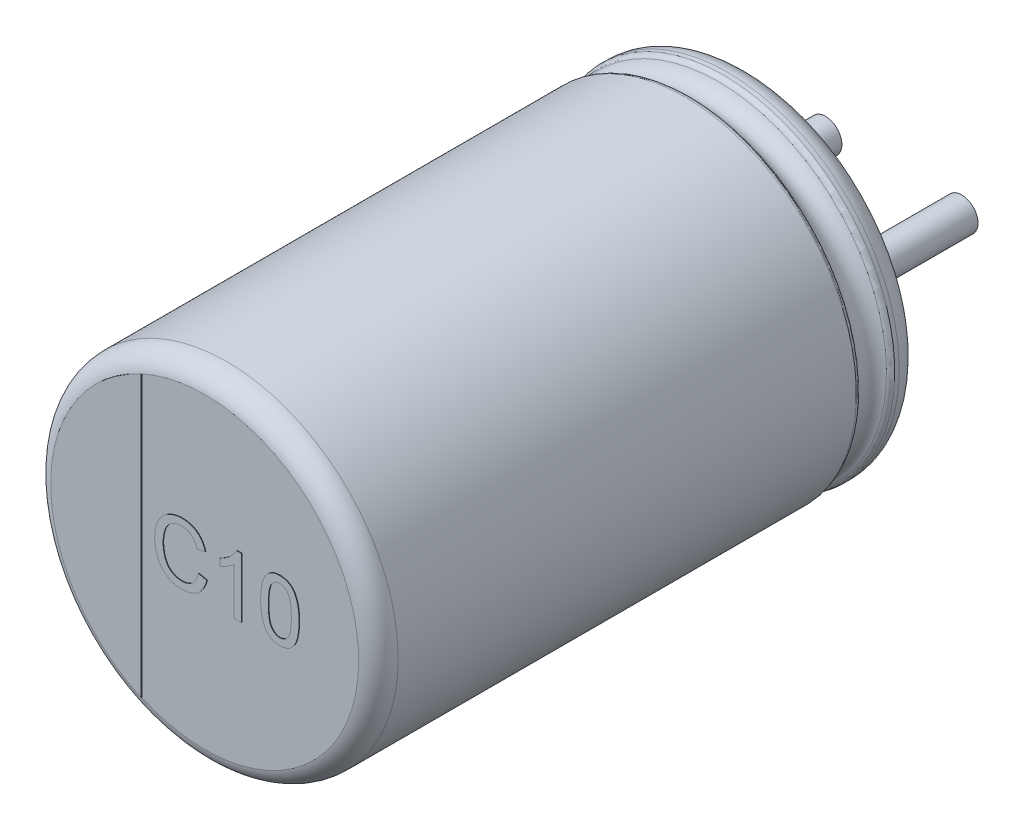
from build123d import *

# Parameters (mm, degrees)
SKETCH_2_R         = 0.3
EXTRUDE_1_DEPTH    = 2.7
EXTRUDE_2_DEPTH    = 0.01
EXTRUDE_1856_DEPTH = 0.01
EXTRUDE_5_DEPTH    = 0.05


with BuildPart() as part:
    # Sketch10 → Повернуть1 (revolve)
    with BuildSketch(Plane(origin=(0, 0, 0), x_dir=(0, 0, -1), z_dir=(1, 0, 0))):
        with BuildLine():
            Line((-10, 0), (-0.05, 0))
            Line((-0.05, 0), (-0.05, 2.553143426))
            ThreePointArc((-0.05, 2.553143426), (-0.052704561, 2.951565585), (-0.398206102, 3.15))
            Line((-0.398206102, 3.15), (-0.479422929, 3.15))
            ThreePointArc((-0.479422929, 3.15), (-0.534479696, 3.133479053), (-0.571344666, 3.089375046))
            ThreePointArc((-0.571344666, 3.089375046), (-0.831990181, 2.917472047), (-1.092635697, 3.089375046))
            ThreePointArc((-1.092635697, 3.089375046), (-1.129500666, 3.133479053), (-1.184557434, 3.15))
            Line((-1.184557434, 3.15), (-9.6, 3.15))
            ThreePointArc((-9.6, 3.15), (-9.85971595, 3.059961924), (-10, 2.82357323))
            Line((-10, 2.82357323), (-10, 0))
        make_face()
    revolve(axis=Axis((0, 0, -18.1630778), (0, 0, 1)))

    # Эскиз2 → Бобышка-Вытянуть1 (add)
    with BuildSketch(Plane(origin=(0, 0, 0.05), x_dir=(-1, 0, 0), z_dir=(0, 0, -1))):
        with Locations((-1.25, 0)):
            Circle(SKETCH_2_R)
        with Locations((1.25, 0)):
            Circle(SKETCH_2_R)
    extrude(amount=EXTRUDE_1_DEPTH)

    # Эскиз4 → Бобышка-Вытянуть2 (add)
    with BuildSketch(Plane.XY.offset(10)):
        with BuildLine():
            Line((-1.160332513, -2.574139515), (-1.160332513, 2.574139515))
            ThreePointArc((-1.160332513, 2.574139515), (-2.82357323, 0), (-1.160332513, -2.574139515))
        make_face()
    extrude(amount=EXTRUDE_2_DEPTH)

    # Эскиз5 → Extrude 1856 (add)
    with BuildSketch(Plane.XY.offset(10)):
        with BuildLine():
            Line((-0.108912855, -0.069918347), (0.04621535, -0.106056167))
            add(Edge.make_bspline(
                [(0.04621535, -0.106056167), (0.042328955, -0.120595903), (0.034726685, -0.149037431), (0.019696074, -0.189740405), (0.002826055, -0.22793841), (-0.016292712, -0.263530826), (-0.037869483, -0.296313018), (-0.061332559, -0.326706301), (-0.08761128, -0.354073299), (-0.115741448, -0.379045627), (-0.145942088, -0.401071154), (-0.177849082, -0.420090601), (-0.2113082, -0.436272289), (-0.246454673, -0.449579116), (-0.283311287, -0.459593644), (-0.321688266, -0.466892819), (-0.361697515, -0.471388685), (-0.388969191, -0.471980579), (-0.402863176, -0.472282129)],
                knots=[0, 0, 0, 0, 4.5129e-05, 8.8278e-05, 0.000130005, 0.00017033, 0.000209322, 0.000247627, 0.000285345, 0.000322969, 0.000360344, 0.000397303, 0.00043426, 0.000471708, 0.000509877, 0.000548685, 0.000588812, 0.000630487, 0.000630487, 0.000630487, 0.000630487], degree=3))
            add(Edge.make_bspline(
                [(-0.402863176, -0.472282129), (-0.417118674, -0.472075022), (-0.445008416, -0.471669834), (-0.48586528, -0.468374144), (-0.524724169, -0.462658281), (-0.561512517, -0.454716909), (-0.596354147, -0.444897895), (-0.629104581, -0.432544706), (-0.659706455, -0.417746474), (-0.68841503, -0.40091706), (-0.715108371, -0.381798088), (-0.740393493, -0.360905526), (-0.763656558, -0.337664227), (-0.785479231, -0.312622937), (-0.805386205, -0.285451329), (-0.824109863, -0.25651854), (-0.840736314, -0.225314775), (-0.855881721, -0.192418552), (-0.869175168, -0.158148367), (-0.880935219, -0.12318115), (-0.890549703, -0.087447226), (-0.898827154, -0.051247288), (-0.904840321, -0.01427674), (-0.90961459, 0.023187027), (-0.912239578, 0.061373697), (-0.912584999, 0.087042498), (-0.912759009, 0.09997348)],
                knots=[0, 0, 0, 0, 4.2763e-05, 8.3662e-05, 0.000122865, 0.000160509, 0.000196497, 0.000231366, 0.000265367, 0.000298359, 0.00033107, 0.000363769, 0.000396646, 0.000429606, 0.00046332, 0.000497611, 0.000532907, 0.000569289, 0.000606199, 0.00064313, 0.000679908, 0.000717169, 0.000754481, 0.000792226, 0.000830438, 0.00086923, 0.00086923, 0.00086923, 0.00086923], degree=3))
            add(Edge.make_bspline(
                [(-0.912759009, 0.09997348), (-0.912510138, 0.113932996), (-0.912018432, 0.141513475), (-0.909242757, 0.182209272), (-0.904144849, 0.221485694), (-0.897065337, 0.259368577), (-0.888106922, 0.295888601), (-0.877048763, 0.331063557), (-0.864030746, 0.364848441), (-0.849092557, 0.397280506), (-0.83213495, 0.427997725), (-0.81366404, 0.457043765), (-0.793239225, 0.483941703), (-0.771466071, 0.509205432), (-0.747800778, 0.532414283), (-0.72231561, 0.553620827), (-0.695230442, 0.573018497), (-0.666549228, 0.590427213), (-0.636646863, 0.605702449), (-0.605967495, 0.619308236), (-0.574389099, 0.630460027), (-0.542162036, 0.639732294), (-0.509216926, 0.647113879), (-0.475476789, 0.652049968), (-0.4409728, 0.655266706), (-0.417707516, 0.655702651), (-0.405948112, 0.655922999)],
                knots=[0, 0, 0, 0, 4.1881e-05, 8.2747e-05, 0.000122296, 0.00016063, 0.000198308, 0.000235036, 0.00027117, 0.000306859, 0.000342067, 0.000376357, 0.000410027, 0.000443298, 0.000476332, 0.000509341, 0.000542667, 0.000576187, 0.000609892, 0.00064334, 0.000676795, 0.000710271, 0.000743899, 0.000777992, 0.000812505, 0.000847779, 0.000847779, 0.000847779, 0.000847779], degree=3))
            add(Edge.make_bspline(
                [(-0.405948112, 0.655922999), (-0.392790923, 0.655674993), (-0.366929166, 0.655187511), (-0.328981645, 0.651177881), (-0.292637827, 0.64446219), (-0.25774023, 0.635651838), (-0.224651675, 0.623588633), (-0.19301293, 0.609246868), (-0.163138738, 0.592016975), (-0.134796652, 0.572372462), (-0.108448038, 0.5502771), (-0.083724175, 0.526258741), (-0.061633171, 0.499717103), (-0.04130009, 0.471294538), (-0.023364678, 0.440596924), (-0.007167108, 0.407891911), (0.006762331, 0.372936375), (0.014215274, 0.348588877), (0.018010222, 0.336191429)],
                knots=[0, 0, 0, 0, 3.9465e-05, 7.7573e-05, 0.00011431, 0.000150279, 0.000185409, 0.000219821, 0.000254368, 0.000288721, 0.000323141, 0.000357421, 0.000391983, 0.00042659, 0.000462151, 0.000498515, 0.000535996, 0.000574881, 0.000574881, 0.000574881, 0.000574881], degree=3))
            Line((0.018010222, 0.336191429), (-0.137117984, 0.302918192))
            add(Edge.make_bspline(
                [(-0.137117984, 0.302918192), (-0.140164459, 0.312432596), (-0.146127355, 0.331055231), (-0.15671506, 0.357595794), (-0.168149428, 0.382234108), (-0.180702836, 0.404802692), (-0.194402488, 0.425306953), (-0.20893292, 0.443996089), (-0.224642265, 0.460521265), (-0.241210981, 0.47526351), (-0.259066923, 0.487822492), (-0.277791469, 0.498951816), (-0.297779426, 0.508159635), (-0.318743252, 0.515947548), (-0.340878894, 0.521874989), (-0.364096214, 0.526045177), (-0.388415609, 0.528458678), (-0.404987911, 0.528817113), (-0.413440099, 0.528999922)],
                knots=[0, 0, 0, 0, 2.9963e-05, 5.8647e-05, 8.5657e-05, 0.000111404, 0.000136034, 0.000159573, 0.00018233, 0.000204345, 0.00022599, 0.00024772, 0.000269605, 0.000291914, 0.000314738, 0.000338251, 0.000362611, 0.000387967, 0.000387967, 0.000387967, 0.000387967], degree=3))
            add(Edge.make_bspline(
                [(-0.413440099, 0.528999922), (-0.423143984, 0.528859129), (-0.442228662, 0.528582229), (-0.47026635, 0.525551592), (-0.497192283, 0.52108776), (-0.522805782, 0.51439386), (-0.547247006, 0.506048307), (-0.570370917, 0.495656617), (-0.592374217, 0.483476338), (-0.613011338, 0.469434324), (-0.632108844, 0.453648399), (-0.650184985, 0.436960206), (-0.666371907, 0.418591447), (-0.681286864, 0.399147811), (-0.694495535, 0.378285716), (-0.706385552, 0.356289328), (-0.716881124, 0.332978371), (-0.72832201, 0.300169965), (-0.739987527, 0.257913496), (-0.750107378, 0.206205274), (-0.756553484, 0.153682392), (-0.757270938, 0.118354545), (-0.757630804, 0.100634538)],
                knots=[0, 0, 0, 0, 2.91e-05, 5.7231e-05, 8.4509e-05, 0.000110911, 0.000136555, 0.000161905, 0.00018686, 0.000211918, 0.000236663, 0.000261138, 0.00028564, 0.000310012, 0.000334585, 0.000359628, 0.000384977, 0.000411183, 0.00046379, 0.000516339, 0.000569145, 0.000622287, 0.000622287, 0.000622287, 0.000622287], degree=3))
            add(Edge.make_bspline(
                [(-0.757630804, 0.100634538), (-0.757224926, 0.078354594), (-0.756437487, 0.035129485), (-0.748667393, -0.027510838), (-0.73682082, -0.085937398), (-0.722523713, -0.131521756), (-0.708182278, -0.165145637), (-0.696583647, -0.188692925), (-0.683344271, -0.210482444), (-0.668793463, -0.230637938), (-0.652743794, -0.249100614), (-0.635418867, -0.265968548), (-0.616814812, -0.281404048), (-0.59671119, -0.29468455), (-0.575881813, -0.306476479), (-0.554589531, -0.316962087), (-0.53282094, -0.32583035), (-0.51048821, -0.332719396), (-0.487904955, -0.338672491), (-0.464822442, -0.342561331), (-0.441247254, -0.34475607), (-0.425417098, -0.345156447), (-0.417406445, -0.345359052)],
                knots=[0, 0, 0, 0, 6.6811e-05, 0.000129619, 0.000189041, 0.000245488, 0.000272541, 0.000298655, 0.000324164, 0.000348934, 0.000373146, 0.000397455, 0.000421409, 0.000445549, 0.000469628, 0.000493181, 0.000516709, 0.000540055, 0.00056325, 0.000586724, 0.000610185, 0.00063422, 0.00063422, 0.00063422, 0.00063422], degree=3))
            add(Edge.make_bspline(
                [(-0.417406445, -0.345359052), (-0.407846827, -0.345158567), (-0.388963202, -0.344762537), (-0.361277409, -0.34129607), (-0.334588687, -0.336187777), (-0.309220365, -0.328305166), (-0.284831211, -0.318653832), (-0.261621051, -0.306752049), (-0.239662879, -0.292437677), (-0.218698419, -0.276185053), (-0.199114272, -0.257692345), (-0.181166455, -0.237108537), (-0.165065235, -0.214339793), (-0.150135352, -0.189751516), (-0.137591507, -0.162609165), (-0.125972944, -0.133721734), (-0.116291518, -0.102614431), (-0.111407741, -0.080973603), (-0.108912855, -0.069918347)],
                knots=[0, 0, 0, 0, 2.8667e-05, 5.6627e-05, 8.3593e-05, 0.000110082, 0.000136188, 0.000162205, 0.000188181, 0.000214716, 0.000241683, 0.000268859, 0.000296498, 0.000325256, 0.000355023, 0.00038608, 0.000418627, 0.000452619, 0.000452619, 0.000452619, 0.000452619], degree=3))
        make_face()
        with BuildLine():
            Line((0.680830734, -0.458179565), (0.539805093, -0.458179565))
            Line((0.539805093, -0.458179565), (0.539805093, 0.39899191))
            add(Edge.make_bspline(
                [(0.539805093, 0.39899191), (0.531684824, 0.391160909), (0.514807735, 0.374885033), (0.486278799, 0.351850605), (0.454436861, 0.328504235), (0.419695408, 0.30605409), (0.384282373, 0.2849197), (0.350060235, 0.265912566), (0.317600345, 0.249827918), (0.296218841, 0.241032769), (0.285958939, 0.236812422)],
                knots=[0, 0, 0, 0, 3.3829e-05, 7.031e-05, 0.000109888, 0.000152243, 0.000194341, 0.000233594, 0.000269662, 0.000302936, 0.000302936, 0.000302936, 0.000302936], degree=3))
            Line((0.285958939, 0.236812422), (0.285958939, 0.366820435))
            add(Edge.make_bspline(
                [(0.285958939, 0.366820435), (0.30358138, 0.375896028), (0.338314168, 0.393783483), (0.387384086, 0.424677577), (0.433196134, 0.458168047), (0.474991939, 0.494247477), (0.512459216, 0.531127132), (0.544033433, 0.568340152), (0.57045273, 0.60452247), (0.583707791, 0.629755623), (0.590045478, 0.641820435)],
                knots=[0, 0, 0, 0, 5.9443e-05, 0.000117159, 0.000173749, 0.000229533, 0.000282665, 0.000331279, 0.00037585, 0.000416686, 0.000416686, 0.000416686, 0.000416686], degree=3))
            Line((0.590045478, 0.641820435), (0.680830734, 0.641820435))
            Line((0.680830734, 0.641820435), (0.680830734, -0.458179565))
        make_face()
        with BuildLine():
            add(Edge.make_bspline(
                [(1.033394837, 0.084328448), (1.03353692, 0.100048458), (1.033815202, 0.130837337), (1.035541291, 0.175886998), (1.038554904, 0.218668796), (1.043053398, 0.259145577), (1.048380458, 0.297408704), (1.055305669, 0.333403573), (1.063097538, 0.367210943), (1.072446383, 0.398795576), (1.082717703, 0.428429042), (1.094370843, 0.456063803), (1.107482207, 0.481670559), (1.121407451, 0.505514867), (1.136879631, 0.527225849), (1.152964876, 0.547412804), (1.170832165, 0.565335399), (1.189738538, 0.581454782), (1.209962397, 0.595679199), (1.231396738, 0.607953155), (1.253959086, 0.618790173), (1.278079455, 0.626948277), (1.303257111, 0.633598862), (1.329685859, 0.638491112), (1.357394822, 0.641375259), (1.376330004, 0.641670367), (1.385958939, 0.641820435)],
                knots=[0, 0, 0, 0, 4.716e-05, 9.2367e-05, 0.000135226, 0.000175791, 0.000214526, 0.000251087, 0.000285722, 0.000318563, 0.000349854, 0.000379772, 0.000408449, 0.000436112, 0.000462522, 0.000488367, 0.000513454, 0.00053831, 0.000562825, 0.000587506, 0.000612346, 0.000637782, 0.000663757, 0.000690424, 0.000718336, 0.000747215, 0.000747215, 0.000747215, 0.000747215], degree=3))
            add(Edge.make_bspline(
                [(1.385958939, 0.641820435), (1.400085841, 0.641405114), (1.427838706, 0.6405892), (1.468358031, 0.633934748), (1.506544884, 0.622551284), (1.542374454, 0.607194499), (1.575234241, 0.587688427), (1.604579416, 0.563975825), (1.630093444, 0.536305669), (1.651497878, 0.504350079), (1.670207489, 0.468990602), (1.686828698, 0.430068533), (1.701853788, 0.387627487), (1.712515918, 0.349636826), (1.720121207, 0.31684194), (1.725155304, 0.289793645), (1.729334614, 0.260608383), (1.73253653, 0.229356761), (1.735163627, 0.196073829), (1.737192413, 0.160738865), (1.73822223, 0.123263557), (1.738420892, 0.09755012), (1.738523042, 0.084328448)],
                knots=[0, 0, 0, 0, 4.2365e-05, 8.3228e-05, 0.000122759, 0.000161647, 0.00019989, 0.000237023, 0.00027445, 0.000312344, 0.000352072, 0.000394316, 0.000439198, 0.000487052, 0.000512602, 0.000540175, 0.000569562, 0.000601026, 0.000634404, 0.000669716, 0.000707192, 0.000746858, 0.000746858, 0.000746858, 0.000746858], degree=3))
            add(Edge.make_bspline(
                [(1.738523042, 0.084328448), (1.738378297, 0.068682277), (1.73809551, 0.038114404), (1.736415672, -0.006574035), (1.733220468, -0.049033065), (1.729288711, -0.089359948), (1.723340787, -0.127447029), (1.716931576, -0.163456131), (1.709004965, -0.197223741), (1.699756472, -0.228764657), (1.689340568, -0.258245658), (1.677917917, -0.285889544), (1.665266235, -0.311677426), (1.65100896, -0.335357781), (1.635798425, -0.357244927), (1.619523232, -0.377420967), (1.601838325, -0.39559551), (1.582761576, -0.411666544), (1.562679714, -0.42614321), (1.541193262, -0.438538347), (1.518396265, -0.448807503), (1.494441037, -0.45758712), (1.469084518, -0.464020309), (1.442526668, -0.468944815), (1.414669632, -0.471844721), (1.395661211, -0.472134314), (1.385958939, -0.472282129)],
                knots=[0, 0, 0, 0, 4.694e-05, 9.1706e-05, 0.000134126, 0.000174667, 0.000213216, 0.000249737, 0.000284372, 0.000317213, 0.000348296, 0.000378129, 0.000406904, 0.000434377, 0.000460968, 0.000486813, 0.000512057, 0.000536914, 0.000561556, 0.000586236, 0.000611184, 0.000636486, 0.000662674, 0.000689557, 0.000717469, 0.000746569, 0.000746569, 0.000746569, 0.000746569], degree=3))
            add(Edge.make_bspline(
                [(1.385958939, -0.472282129), (1.373238137, -0.471919267), (1.348436073, -0.471211787), (1.312214487, -0.466404895), (1.278218597, -0.457944539), (1.246161667, -0.446598009), (1.216404024, -0.431421372), (1.188803589, -0.412956029), (1.162805751, -0.391631596), (1.147839815, -0.374807108), (1.140265831, -0.366292546)],
                knots=[0, 0, 0, 0, 3.8162e-05, 7.4405e-05, 0.000109357, 0.000143093, 0.000176205, 0.000209268, 0.000242588, 0.000276728, 0.000276728, 0.000276728, 0.000276728], degree=3))
            add(Edge.make_bspline(
                [(1.140265831, -0.366292546), (1.131548, -0.353716948), (1.113571462, -0.327785527), (1.092531482, -0.283570049), (1.073763447, -0.234895016), (1.059033981, -0.180805429), (1.047497137, -0.12173178), (1.039164656, -0.057558155), (1.034449292, 0.011687722), (1.033754256, 0.059568265), (1.033394837, 0.084328448)],
                knots=[0, 0, 0, 0, 4.5838e-05, 9.4519e-05, 0.00014641, 0.000202225, 0.000262423, 0.000326872, 0.000396232, 0.000470512, 0.000470512, 0.000470512, 0.000470512], degree=3))
        make_face()
        with BuildLine():
            add(Edge.make_bspline(
                [(1.174420478, 0.084769153), (1.174560505, 0.063612152), (1.174828548, 0.023112973), (1.177628948, -0.034747093), (1.182449722, -0.086944769), (1.188823099, -0.133407787), (1.197238537, -0.174198995), (1.207805116, -0.209214445), (1.219716163, -0.238874403), (1.234455857, -0.262811255), (1.250594195, -0.282323282), (1.267255926, -0.299104255), (1.284833043, -0.313367699), (1.303210857, -0.325260502), (1.322674514, -0.334264951), (1.343011182, -0.340791396), (1.364225285, -0.344547265), (1.378673053, -0.345086912), (1.385958939, -0.345359052)],
                knots=[0, 0, 0, 0, 6.3468e-05, 0.000121491, 0.00017372, 0.000220682, 0.000262127, 0.000298514, 0.000330313, 0.000357712, 0.000382457, 0.00040614, 0.000428544, 0.000450244, 0.000471636, 0.000492682, 0.000514165, 0.000536019, 0.000536019, 0.000536019, 0.000536019], degree=3))
            add(Edge.make_bspline(
                [(1.385958939, -0.345359052), (1.393243002, -0.345080966), (1.407687152, -0.344529527), (1.428950272, -0.340856479), (1.449207814, -0.333994057), (1.468642451, -0.325021412), (1.487153841, -0.313399681), (1.504644631, -0.299082362), (1.521394133, -0.282311352), (1.537459977, -0.262572534), (1.552087376, -0.238525013), (1.56422186, -0.208889217), (1.574623764, -0.173812444), (1.58308538, -0.133042019), (1.589485048, -0.086652463), (1.594276674, -0.034599559), (1.597095815, 0.02318606), (1.597359435, 0.063612057), (1.597497401, 0.084769153)],
                knots=[0, 0, 0, 0, 2.1855e-05, 4.3338e-05, 6.4452e-05, 8.5844e-05, 0.000107426, 0.00012983, 0.000153513, 0.000178429, 0.000206016, 0.000237612, 0.000274209, 0.000315655, 0.000362399, 0.000414627, 0.000472431, 0.000535899, 0.000535899, 0.000535899, 0.000535899], degree=3))
            add(Edge.make_bspline(
                [(1.597497401, 0.084769153), (1.597363852, 0.105486039), (1.597107978, 0.145178808), (1.594216127, 0.201924198), (1.589684338, 0.253245758), (1.583485569, 0.299190802), (1.575247408, 0.339709451), (1.565255641, 0.374887963), (1.553348957, 0.404651314), (1.539191953, 0.429298478), (1.523432374, 0.449515839), (1.50697, 0.467015724), (1.48939327, 0.481898806), (1.470390777, 0.493838234), (1.450575007, 0.50347052), (1.429490644, 0.510099705), (1.407344931, 0.514172469), (1.392146615, 0.514652968), (1.384416472, 0.514897358)],
                knots=[0, 0, 0, 0, 6.2146e-05, 0.000119069, 0.0001704, 0.000216676, 0.000258077, 0.000294338, 0.000326256, 0.000353997, 0.000379296, 0.000402987, 0.000425981, 0.000448171, 0.00047015, 0.000491893, 0.000514282, 0.000537457, 0.000537457, 0.000537457, 0.000537457], degree=3))
            add(Edge.make_bspline(
                [(1.384416472, 0.514897358), (1.377131043, 0.514706145), (1.36276511, 0.514329095), (1.341731504, 0.510730166), (1.321798202, 0.504711955), (1.302736833, 0.496559703), (1.285023256, 0.485588382), (1.267954992, 0.472778584), (1.252331453, 0.457171275), (1.242916846, 0.445503494), (1.238102369, 0.439536781)],
                knots=[0, 0, 0, 0, 2.1843e-05, 4.3071e-05, 6.3776e-05, 8.4203e-05, 0.000105064, 0.00012613, 0.0001481, 0.000171094, 0.000171094, 0.000171094, 0.000171094], degree=3))
            add(Edge.make_bspline(
                [(1.238102369, 0.439536781), (1.232860872, 0.430773528), (1.221791935, 0.412267382), (1.209406438, 0.380102939), (1.19846558, 0.343345102), (1.189457626, 0.301428326), (1.182941004, 0.254424515), (1.177796382, 0.202388255), (1.175123942, 0.145246897), (1.174661436, 0.105484601), (1.174420478, 0.084769153)],
                knots=[0, 0, 0, 0, 3.0585e-05, 6.4588e-05, 0.000103001, 0.000145616, 0.000193046, 0.000245295, 0.000302439, 0.000364588, 0.000364588, 0.000364588, 0.000364588], degree=3))
        make_face(mode=Mode.SUBTRACT)
    extrude(amount=EXTRUDE_1856_DEPTH)

    # Эскиз6 → Бобышка-Вытянуть5 (add)
    with BuildSketch(Plane(origin=(0, 0, 0.05), x_dir=(-1, 0, 0), z_dir=(0, 0, -1))):
        with BuildLine():
            Line((-1.25, 0.4), (-1.624807681, 0.4))
            ThreePointArc((-1.624807681, 0.4), (-1.831827349, 0.509847022), (-1.856923064, 0.742857143))
            ThreePointArc((-1.856923064, 0.742857143), (0, 2), (1.856923064, 0.742857143))
            ThreePointArc((1.856923064, 0.742857143), (1.831827349, 0.509847022), (1.624807681, 0.4))
            Line((1.624807681, 0.4), (1.25, 0.4))
            ThreePointArc((1.25, 0.4), (0.85, 0), (1.25, -0.4))
            Line((1.25, -0.4), (1.624807681, -0.4))
            ThreePointArc((1.624807681, -0.4), (1.831827349, -0.509847022), (1.856923064, -0.742857143))
            ThreePointArc((1.856923064, -0.742857143), (0, -2), (-1.856923064, -0.742857143))
            ThreePointArc((-1.856923064, -0.742857143), (-1.831827349, -0.509847022), (-1.624807681, -0.4))
            Line((-1.624807681, -0.4), (-1.25, -0.4))
            ThreePointArc((-1.25, -0.4), (-0.85, 0), (-1.25, 0.4))
        make_face()
    extrude(amount=EXTRUDE_5_DEPTH)


solid = part.part
